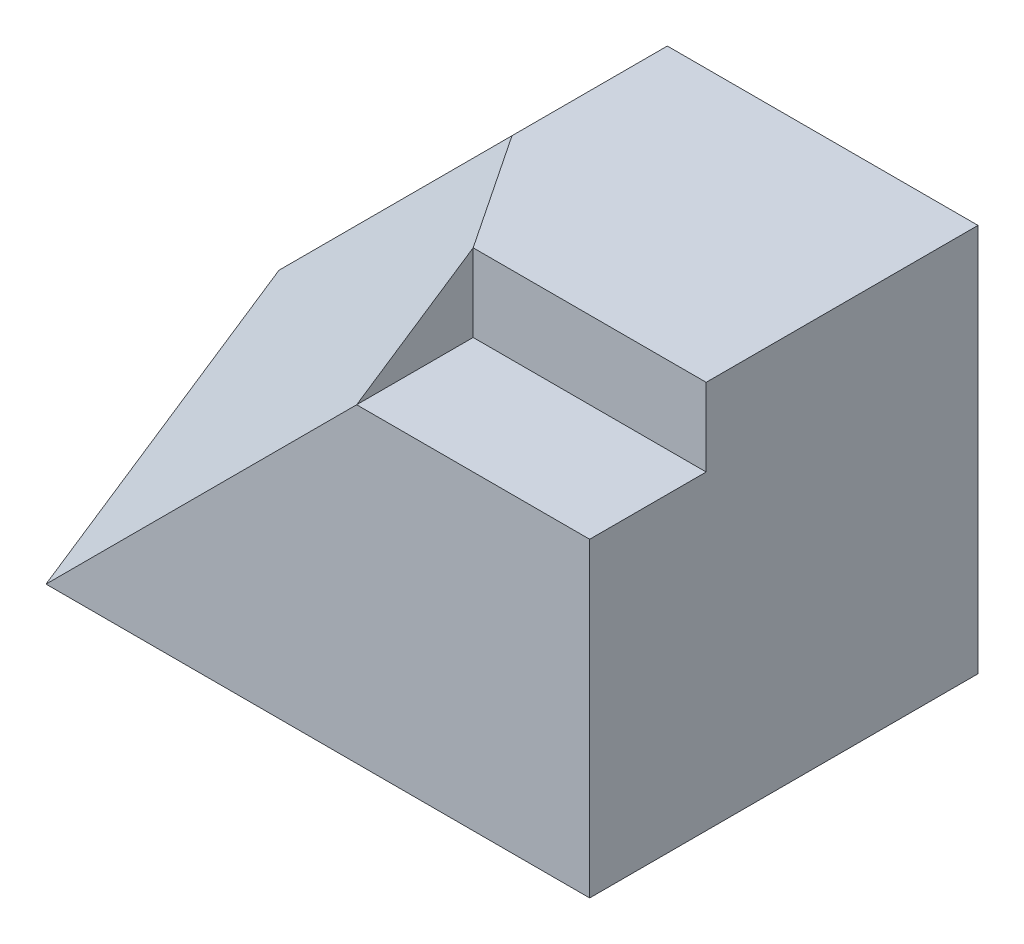
from build123d import *

# Parameters (mm, degrees)
SKETCH1_W           = 70
SKETCH1_H           = 50
BOSS_EXTRUDE1_DEPTH = 50
CUT_EXTRUDE1_DEPTH  = 50
CUT_EXTRUDE3_DEPTH  = 30
BOSS_EXTRUDE2_DEPTH = 30
SKETCH6_W           = 70
SKETCH6_H           = 50
CUT_EXTRUDE4_DEPTH  = 30
BOSS_EXTRUDE3_DEPTH = 30
SKETCH8_W           = 30
SKETCH8_H           = 10
CUT_EXTRUDE6_DEPTH  = 15
BOSS_EXTRUDE4_DEPTH = 15
BOSS_EXTRUDE5_DEPTH = 15
SKETCH11_W          = 15
SKETCH11_H          = 10
CUT_EXTRUDE8_DEPTH  = 30


with BuildPart() as part:
    # Sketch1 → Boss-Extrude1 (new body)
    with BuildSketch(Plane.XY):
        with Locations((35, 25)):
            Rectangle(SKETCH1_W, SKETCH1_H)
    extrude(amount=BOSS_EXTRUDE1_DEPTH)

    # Sketch2 → Cut-Extrude1 (cut)
    with BuildSketch(Plane.XY.offset(50)):
        Polygon((0, 20), (30, 50), (0, 50), align=None)
    extrude(amount=-CUT_EXTRUDE1_DEPTH, mode=Mode.SUBTRACT)

    # Sketch3 → Cut-Extrude3 (cut)
    with BuildSketch(Plane.XY.offset(50)):
        Polygon((0, 0), (40, 40), (40, 50), (30, 50), (0, 20), align=None)
    extrude(amount=-CUT_EXTRUDE3_DEPTH, mode=Mode.SUBTRACT)

    # Sketch4 → Boss-Extrude2 (add)
    with BuildSketch(Plane(origin=(-13.636363636, 13.636363636, 9.090909091), x_dir=(0.768706115, 0.532181156, 0.354787438), z_dir=(-0.639602149, 0.639602149, 0.426401433))):
        Polygon((17.73937188, -5.547001962), (17.73937188, -41.602514717), (69.774862727, -19.414506868), (56.765990015, 11.094003925), align=None)
    extrude(amount=-BOSS_EXTRUDE2_DEPTH)

    # Sketch6 → Cut-Extrude4 (cut)
    with BuildSketch(Plane.XZ):
        with Locations((35, 25)):
            Rectangle(SKETCH6_W, SKETCH6_H)
    extrude(amount=CUT_EXTRUDE4_DEPTH, mode=Mode.SUBTRACT)

    # Sketch7 → Boss-Extrude3 (add)
    with BuildSketch(Plane.ZY):
        Polygon((20, 20), (20, 0), (50, 0), align=None)
    extrude(amount=-BOSS_EXTRUDE3_DEPTH)

    # Sketch8 → Cut-Extrude6 (cut)
    with BuildSketch(Plane.XY.offset(50)):
        with Locations((55, 45)):
            Rectangle(SKETCH8_W, SKETCH8_H)
    extrude(amount=-CUT_EXTRUDE6_DEPTH, mode=Mode.SUBTRACT)

    # Sketch9 → Boss-Extrude4 (add)
    with BuildSketch(Plane(origin=(-13.636363636, 13.636363636, 9.090909091), x_dir=(-0.768706115, -0.532181156, -0.354787438), z_dir=(0.639602149, -0.639602149, -0.426401433))):
        Polygon((-56.765990015, 11.094003925), (-69.774862727, -19.414506868), (-69.774862727, -1.386750491), align=None)
    extrude(amount=BOSS_EXTRUDE4_DEPTH)

    # Sketch10 → Boss-Extrude5 (add)
    with BuildSketch(Plane(origin=(0, 50, 0), x_dir=(1, 0, 0), z_dir=(0, 1, 0))):
        Polygon((30, -20), (40, -20), (40, -35), align=None)
    extrude(amount=-BOSS_EXTRUDE5_DEPTH)

    # Sketch11 → Cut-Extrude8 (cut)
    with BuildSketch(Plane(origin=(70, 0, 0), x_dir=(0, 0, -1), z_dir=(1, 0, 0))):
        with Locations((-42.5, 45)):
            Rectangle(SKETCH11_W, SKETCH11_H)
    extrude(amount=-CUT_EXTRUDE8_DEPTH, mode=Mode.SUBTRACT)


solid = part.part
